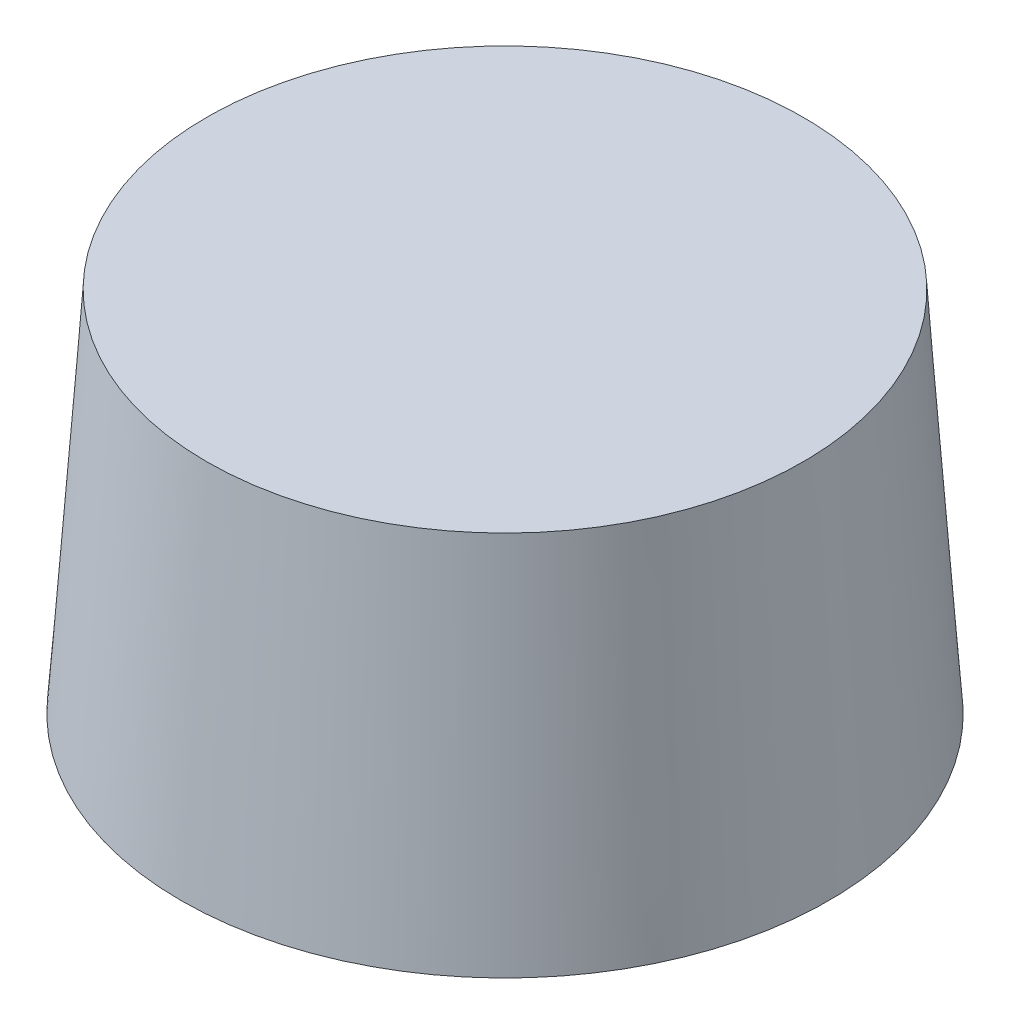
from build123d import *

# Parameters (mm, degrees)
SKETCH_1_R      = 32.5
EXTRUDE_1_DEPTH = 40
DRAFT_1_ANGLE   = 4


with BuildPart() as part:
    # 草图1 → 凸台-拉伸1 (new body)
    with BuildSketch(Plane(origin=(0, 0, 0), x_dir=(1, 0, 0), z_dir=(0, 1, 0))):
        Circle(SKETCH_1_R)
    extrude(amount=EXTRUDE_1_DEPTH)

    # 拔模1
    draft_1_faces = [part.faces().sort_by_distance(p)[0] for p in [
        (-32.5, 20, 0),
    ]]
    draft(draft_1_faces, Plane.ZX.offset(40), DRAFT_1_ANGLE)


solid = part.part
